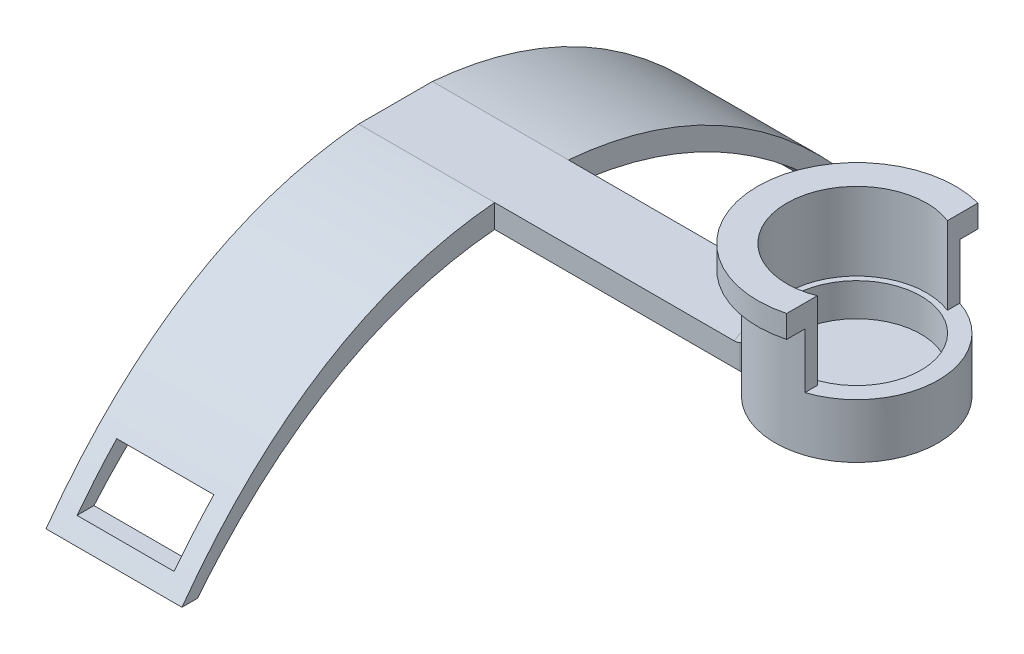
from build123d import *

# Parameters (mm, degrees)
F_0_1MM_FIT_FOR_POT_R   = 10.5
BOSS_EXTRUDE1_DEPTH     = 2.75
SKETCH4_R               = 10.5
SKETCH4_R_2             = 8.275
BOSS_EXTRUDE2_DEPTH     = 4.25
BOSS_EXTRUDE3_DEPTH     = 2
FILLET1_R               = 0.25
BOSS_EXTRUDE6_DEPTH     = 10
BOSS_EXTRUDE7_DEPTH     = 2.9
BOSS_EXTRUDE8_DEPTH     = 3
FILLET2_R               = 1.5
BOSS_EXTRUDE9_DEPTH     = 17.5
SKETCH11_W              = 12.5
SKETCH11_H              = 6
CUT_EXTRUDE1_DEPTH      = 81.518110176
CUT_EXTRUDE1_DEPTH_BACK = 81.518110176


with BuildPart() as part:
    # 0.1mm fit for pot → Boss-Extrude1 (new body)
    with BuildSketch(Plane(origin=(0, 0, 0), x_dir=(1, 0, 0), z_dir=(0, 1, 0))):
        with Locations(Location((0, 0, 0), (0, 0, 270))):
            Circle(F_0_1MM_FIT_FOR_POT_R)
    extrude(amount=BOSS_EXTRUDE1_DEPTH)

    # Sketch4 → Boss-Extrude2 (add)
    with BuildSketch(Plane(origin=(0, 2.75, 0), x_dir=(1, 0, 0), z_dir=(0, 1, 0))):
        with Locations(Location((0, 0, 0), (0, 0, 270))):
            Circle(SKETCH4_R)
        with Locations(Location((0, 0, 0), (0, 0, 270))):
            Circle(SKETCH4_R_2, mode=Mode.SUBTRACT)
    extrude(amount=BOSS_EXTRUDE2_DEPTH)

    # Sketch5 → Boss-Extrude3 (add)
    with BuildSketch(Plane(origin=(0, 2.75, 0), x_dir=(1, 0, 0), z_dir=(0, 1, 0))):
        with BuildLine():
            Line((-1, -8.214354813), (-1, -7.065799598))
            Line((-1, -7.065799598), (0.988059701, -7.065799598))
            Line((0.988059701, -7.065799598), (0.988059701, -8.215799598))
            ThreePointArc((0.988059701, -8.215799598), (-0.006013695, -8.274997815), (-1, -8.214354813))
        make_face()
    extrude(amount=BOSS_EXTRUDE3_DEPTH)

    # Fillet1
    fillet1_edges = [part.edges().sort_by_distance(p)[0] for p in [
        (0.988059701, 3.75, 7.065799598),
        (-1, 3.75, 7.065799598),
        (-0.005970149, 4.75, 7.065799598),
        (-1, 4.75, 7.640077205),
        (0.988059701, 4.75, 7.640799598),
    ]]
    fillet(fillet1_edges, radius=FILLET1_R)

    # Sketch7 → Boss-Extrude6 (add)
    with BuildSketch(Plane(origin=(0, 7, 0), x_dir=(1, 0, 0), z_dir=(0, 1, 0))):
        with BuildLine():
            Line((3.299602194, 9.968080325), (3.299602194, 8.373328213))
            ThreePointArc((3.299602194, 8.373328213), (-9, 0), (3.299602194, -8.373328213))
            Line((3.299602194, -8.373328213), (3.299602194, -9.968080325))
            ThreePointArc((3.299602194, -9.968080325), (-10.5, 0), (3.299602194, 9.968080325))
        make_face()
    extrude(amount=BOSS_EXTRUDE6_DEPTH)

    # Sketch8 → Boss-Extrude7 (add)
    with BuildSketch(Plane(origin=(0, 17, 0), x_dir=(1, 0, 0), z_dir=(0, 1, 0))):
        with BuildLine():
            Line((3.299602194, 12.315645552), (3.299602194, 9.968080325))
            ThreePointArc((3.299602194, 9.968080325), (-10.5, 0), (3.299602194, -9.968080325))
            Line((3.299602194, -9.968080325), (3.299602194, -12.315645552))
            ThreePointArc((3.299602194, -12.315645552), (-12.75, 0), (3.299602194, 12.315645552))
        make_face()
    extrude(amount=-BOSS_EXTRUDE7_DEPTH)

    # Sketch9 → Boss-Extrude8 (add)
    with BuildSketch(Plane.XZ):
        with BuildLine():
            Line((-9.3641604, 4.75), (-59.3641604, 4.75))
            Line((-59.3641604, 4.75), (-59.3641604, -4.75))
            Line((-59.3641604, -4.75), (-9.3641604, -4.75))
            ThreePointArc((-9.3641604, -4.75), (-10.5, 0), (-9.3641604, 4.75))
        make_face()
    extrude(amount=-BOSS_EXTRUDE8_DEPTH)

    # Fillet2
    fillet2_edges = [part.edges().sort_by_distance(p)[0] for p in [
        (-10.5, 3, 0),
        (-9.3641604, 1.5, 4.75),
        (-9.3641604, 1.5, -4.75),
    ]]
    fillet(fillet2_edges, radius=FILLET2_R)

    # Sketch10 → Boss-Extrude9 (add)
    with BuildSketch(Plane.ZY.offset(59.3641604)):
        with BuildLine():
            Line((-45, -22), (-43, -22))
            add(Edge.make_bspline(
                [(-4.75, 0), (-26.762186457, -1.948698647), (-43, -22)],
                knots=[0.548592822, 0.548592822, 0.548592822, 1, 1, 1], degree=2))
            Line((-4.75, 0), (4.75, 0))
            add(Edge.make_bspline(
                [(43, -22), (26.762186461, -1.948698647), (4.75, 0)],
                knots=[0, 0, 0, 0.451407178, 0.451407178, 0.451407178], degree=2))
            Line((43, -22), (45, -22))
            add(Edge.make_bspline(
                [(4.75, 3), (28.386779804, 0.912348176), (45, -22)],
                knots=[0.545557352, 0.545557352, 0.545557352, 1, 1, 1], degree=2))
            Line((4.75, 3), (-4.75, 3))
            add(Edge.make_bspline(
                [(-45, -22), (-28.386779803, 0.912348176), (-4.75, 3)],
                knots=[0, 0, 0, 0.454442648, 0.454442648, 0.454442648], degree=2))
        make_face()
    extrude(amount=-BOSS_EXTRUDE9_DEPTH)

    # Sketch11 → Cut-Extrude1 (cut, two sides)
    with BuildSketch(Plane(origin=(0, 0, -4.75), x_dir=(-1, 0, 0), z_dir=(0, 0, -1))) as cut_extrude1_sk:
        with Locations((50.6141604, -17)):
            Rectangle(SKETCH11_W, SKETCH11_H)
    extrude(amount=CUT_EXTRUDE1_DEPTH, mode=Mode.SUBTRACT)
    extrude(cut_extrude1_sk.sketch, amount=-CUT_EXTRUDE1_DEPTH_BACK, mode=Mode.SUBTRACT)


solid = part.part
